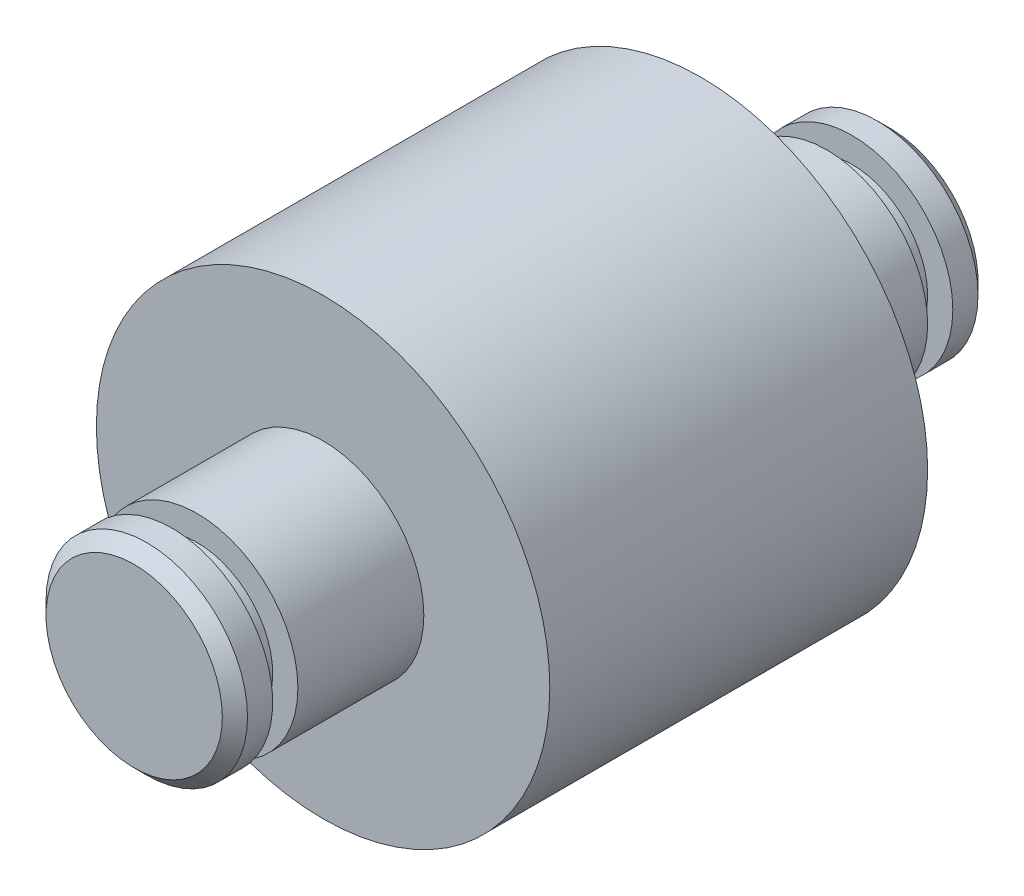
from build123d import *

# Parameters (mm, degrees)
SKETCH1_R                = 9
BOSS_EXTRUDE1_DEPTH      = 7.5
SKETCH2_R                = 4
BOSS_EXTRUDE2_DEPTH      = 7.5
SKETCH3_W                = 1
SKETCH3_H                = 1.613993142
CHAMFER1_SIZE            = 0.5
CHAMFER1_OF_MIRROR1_SIZE = 0.5


with BuildPart() as part:
    # Sketch1 → Boss-Extrude1 (new body)
    with BuildSketch(Plane.XY):
        Circle(SKETCH1_R)
    boss_extrude1 = extrude(amount=BOSS_EXTRUDE1_DEPTH)

    # Sketch2 → Boss-Extrude2 (add)
    with BuildSketch(Plane.XY.offset(7.5)):
        Circle(SKETCH2_R)
    boss_extrude2 = extrude(amount=BOSS_EXTRUDE2_DEPTH)

    # Sketch3 → Cut-Revolve1 (revolve, cut)
    with BuildSketch(Plane(origin=(0, 0, 0), x_dir=(0, 0, -1), z_dir=(1, 0, 0))):
        with Locations((-13, 3.806996571)):
            Rectangle(SKETCH3_W, SKETCH3_H)
    cut_revolve1 = revolve(axis=Axis((0, 0, 15), (0, 0, -1)), mode=Mode.SUBTRACT)

    # Chamfer1
    chamfer1_edges = [part.edges().sort_by_distance(p)[0] for p in [
        (-4, 0, 15),
    ]]
    chamfer(chamfer1_edges, length=CHAMFER1_SIZE)

    # Mirror1: Boss-Extrude1, Boss-Extrude2, Cut-Revolve1 across plane
    add(boss_extrude1.mirror(Plane.XY))
    add(boss_extrude2.mirror(Plane.XY))
    add(cut_revolve1.mirror(Plane.XY), mode=Mode.SUBTRACT)

    # Chamfer1 of Mirror1
    chamfer1_of_mirror1_edges = [part.edges().sort_by_distance(p)[0] for p in [
        (-4, 0, -15),
    ]]
    chamfer(chamfer1_of_mirror1_edges, length=CHAMFER1_OF_MIRROR1_SIZE)


solid = part.part
